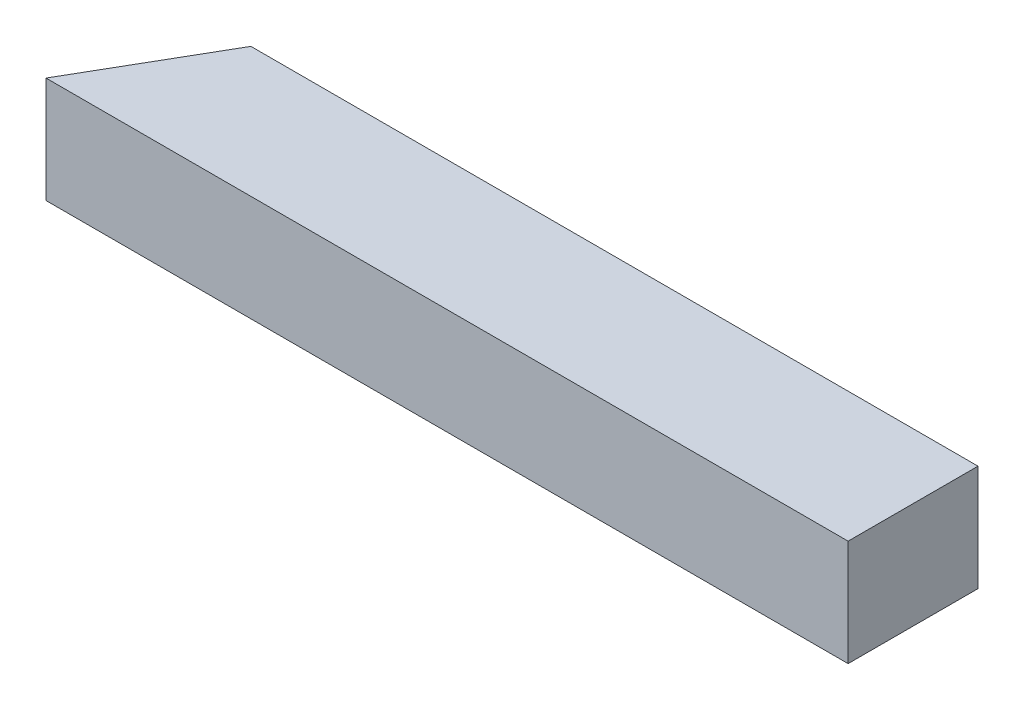
from build123d import *

# Parameters (mm, degrees)
BOSS_EXTRUDE1_DEPTH = 25.4


with BuildPart() as part:
    # Sketch1 → Boss-Extrude1 (new body)
    with BuildSketch(Plane(origin=(0, 0, 0), x_dir=(1, 0, 0), z_dir=(0, 1, 0))):
        Polygon((-128.853566931, 3.590792772), (-146.809160302, -27.509207228), (45.235246326, -27.509207228), (45.235246326, 3.590792772), align=None)
    extrude(amount=BOSS_EXTRUDE1_DEPTH)


solid = part.part
